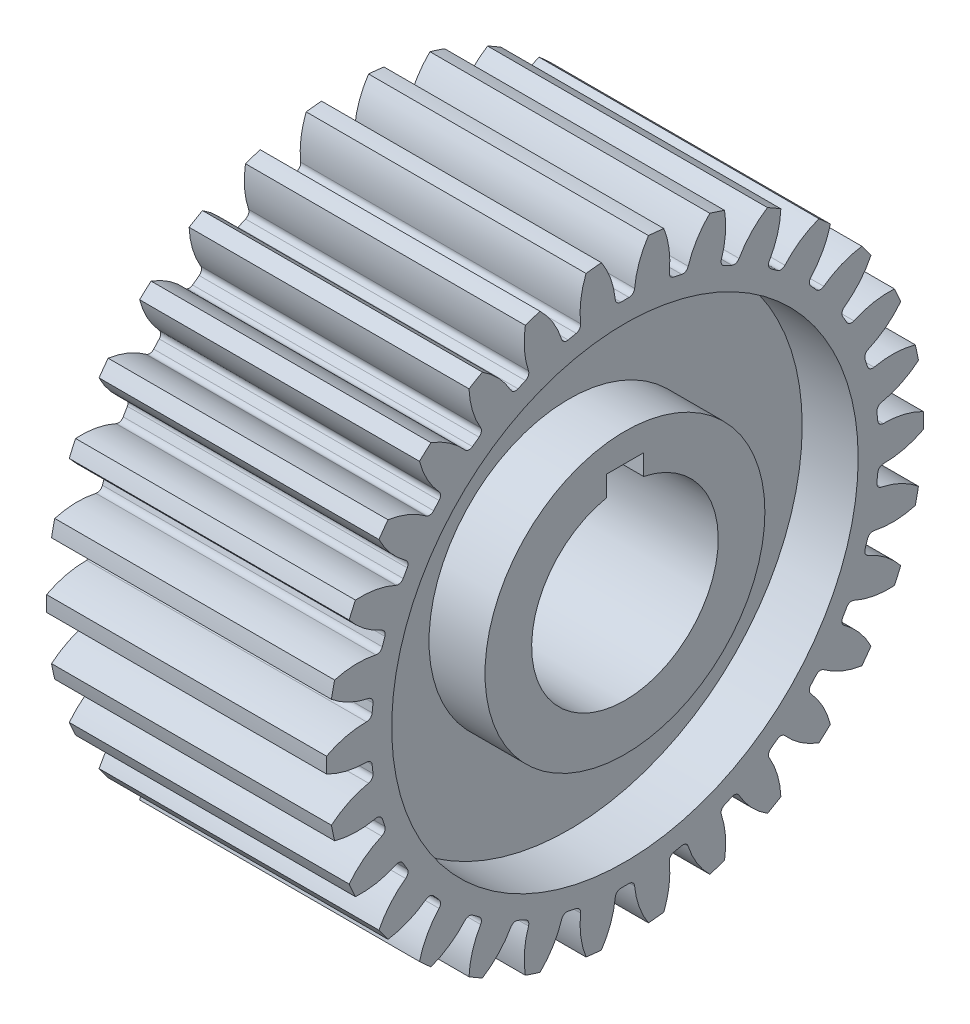
from build123d import *

# Parameters (mm, degrees)
SKETCH1_R           = 16
BOSS_EXTRUDE1_DEPTH = 7.5
CUT_EXTRUDE1_DEPTH  = 16
SKETCH5_R           = 12.5
SKETCH5_R_2         = 7.5
CUT_EXTRUDE2_DEPTH  = 3
CUT_EXTRUDE7_DEPTH  = 16
CIRPATTERN1_COUNT   = 30


with BuildPart() as part:
    # Sketch1 → Boss-Extrude1 (new body, symmetric)
    with BuildSketch(Plane(origin=(0, 0, 0), x_dir=(0, 0, -1), z_dir=(1, 0, 0))):
        Circle(SKETCH1_R)
    extrude(amount=BOSS_EXTRUDE1_DEPTH, both=True)

    # Sketch4 → Cut-Extrude1 (cut, through all)
    with BuildSketch(Plane(origin=(7.5, 0, 0), x_dir=(0, 0, -1), z_dir=(1, 0, 0))):
        with BuildLine():
            Line((-1, 6), (1, 6))
            Line((1, 6), (1, 4.898979486))
            ThreePointArc((1, 4.898979486), (0, -5), (-1, 4.898979486))
            Line((-1, 4.898979486), (-1, 6))
        make_face()
    extrude(amount=-CUT_EXTRUDE1_DEPTH, mode=Mode.SUBTRACT)

    # Sketch5 → Cut-Extrude2 (cut)
    with BuildSketch(Plane(origin=(7.5, 0, 0), x_dir=(0, 0, -1), z_dir=(1, 0, 0))):
        Circle(SKETCH5_R)
        Circle(SKETCH5_R_2, mode=Mode.SUBTRACT)
    cut_extrude2 = extrude(amount=-CUT_EXTRUDE2_DEPTH, mode=Mode.SUBTRACT)

    # Mirror2: Cut-Extrude2 across plane
    add(cut_extrude2.mirror(Plane(origin=(0, 0, 0), x_dir=(0, 0, 1), z_dir=(1, 0, 0))), mode=Mode.SUBTRACT)

    # Sketch9 → Cut-Extrude7 (cut, through all)
    with BuildSketch(Plane(origin=(7.5, 0, 0), x_dir=(0, 0, -1), z_dir=(1, 0, 0))):
        with BuildLine():
            Line((-0.219874756, 13.6), (0.219874756, 13.6))
            ThreePointArc((0.219874756, 13.6), (0.421386888, 13.677754953), (0.518441911, 13.870714262))
            ThreePointArc((0.518441911, 13.870714262), (1.009154991, 15.525876188), (2.08, 16.88))
            ThreePointArc((2.08, 16.88), (0, 17.000581665), (-2.08, 16.88))
            ThreePointArc((-2.08, 16.88), (-1.009154991, 15.525876188), (-0.518441911, 13.870714262))
            ThreePointArc((-0.518441911, 13.870714262), (-0.421386888, 13.677754953), (-0.219874756, 13.6))
        make_face()
    cut_extrude7 = extrude(amount=-CUT_EXTRUDE7_DEPTH, mode=Mode.SUBTRACT)

    # CirPattern1: Cut-Extrude7 ×30 about axis
    cirpattern1_axis = Axis((0, 0, 0), (1, 0, 0))
    for i in range(1, CIRPATTERN1_COUNT):
        add(cut_extrude7.rotate(cirpattern1_axis, i * 360 / CIRPATTERN1_COUNT), mode=Mode.SUBTRACT)


solid = part.part
